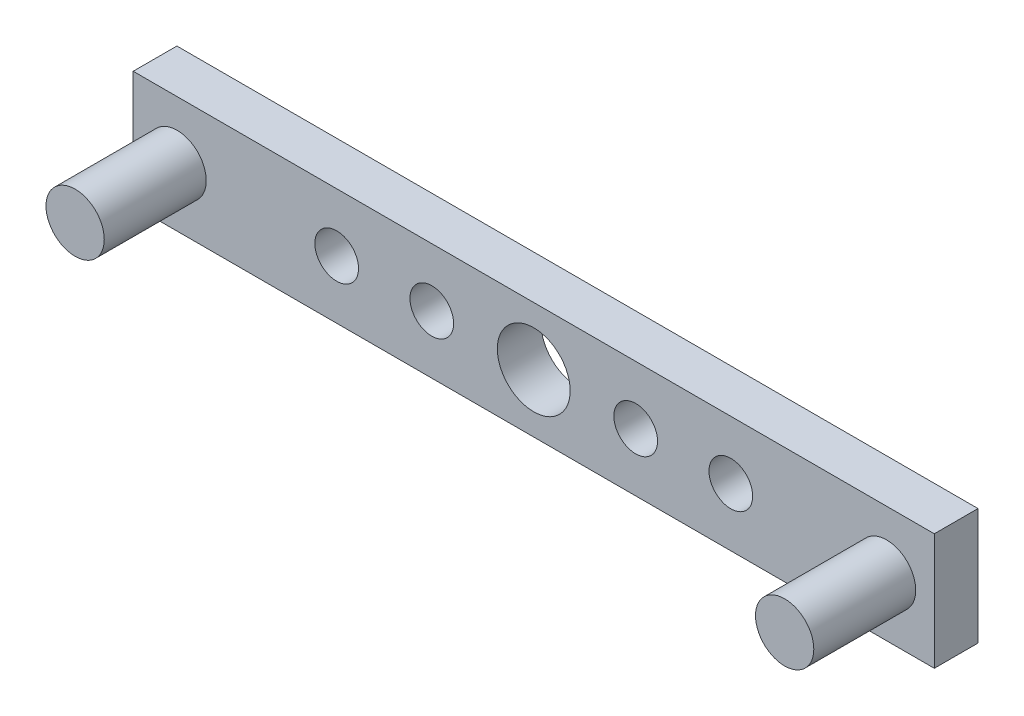
from build123d import *

# Parameters (mm, degrees)
SKETCH1_W           = 55
SKETCH1_H           = 8
BOSS_EXTRUDE1_DEPTH = 3
SKETCH2_R           = 1.5
SKETCH2_R_2         = 2.5
CUT_EXTRUDE1_DEPTH  = 4
SKETCH3_R           = 2
BOSS_EXTRUDE2_DEPTH = 10


with BuildPart() as part:
    # Sketch1 → Boss-Extrude1 (new body)
    with BuildSketch(Plane.XY):
        with Locations((27.5, 4)):
            Rectangle(SKETCH1_W, SKETCH1_H)
    extrude(amount=BOSS_EXTRUDE1_DEPTH)

    # Sketch2 → Cut-Extrude1 (cut, through all)
    with BuildSketch(Plane.XY.offset(3)):
        with Locations((13.97, 4)):
            Circle(SKETCH2_R)
        with Locations((20.5, 4)):
            Circle(SKETCH2_R)
        with Locations((41.03, 4)):
            Circle(SKETCH2_R)
        with Locations((34.5, 4)):
            Circle(SKETCH2_R)
        with Locations((27.5, 4)):
            Circle(SKETCH2_R_2)
    extrude(amount=-CUT_EXTRUDE1_DEPTH, mode=Mode.SUBTRACT)

    # Sketch3 → Boss-Extrude2 (add)
    with BuildSketch(Plane.XY):
        with Locations((51.725977791, 4)):
            Circle(SKETCH3_R)
        with Locations((3.013958935, 4)):
            Circle(SKETCH3_R)
    extrude(amount=BOSS_EXTRUDE2_DEPTH)


solid = part.part
